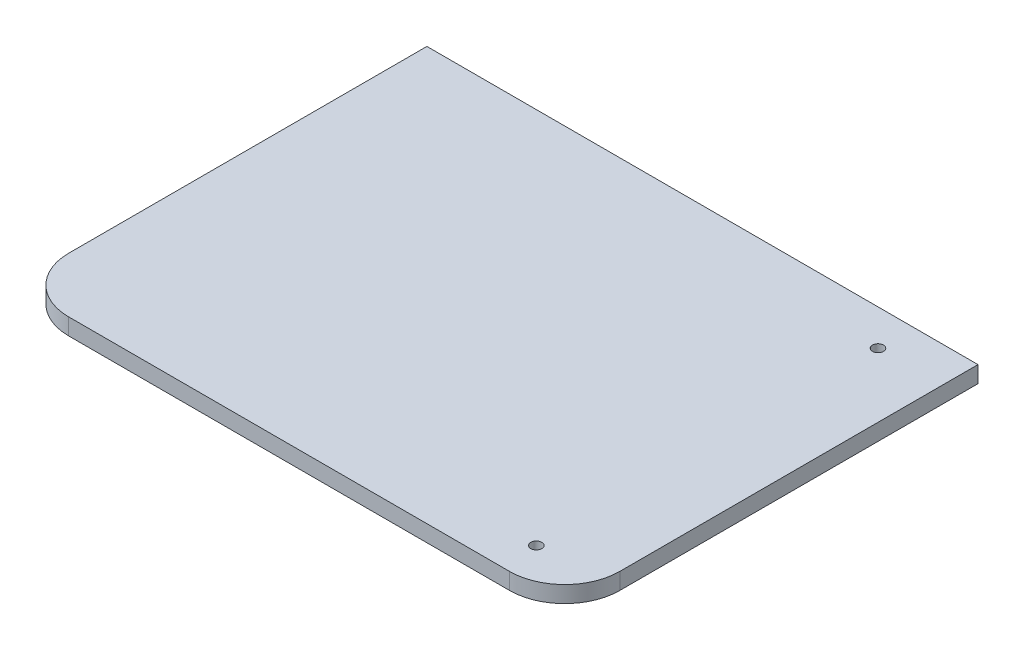
from build123d import *

# Parameters (mm, degrees)
SKETCH1_W           = 100
SKETCH1_H           = 75
BOSS_EXTRUDE1_DEPTH = 3
FILLET1_R           = 10
SKETCH2_R           = 1
CUT_EXTRUDE1_DEPTH  = 4


with BuildPart() as part:
    # Sketch1 → Boss-Extrude1 (new body)
    with BuildSketch(Plane(origin=(0, 0, 0), x_dir=(1, 0, 0), z_dir=(0, 1, 0))):
        Rectangle(SKETCH1_W, SKETCH1_H)
    extrude(amount=BOSS_EXTRUDE1_DEPTH)

    # Fillet1
    fillet1_edges = [part.edges().sort_by_distance(p)[0] for p in [
        (50, 1.5, 37.5),
        (-50, 1.5, 37.5),
    ]]
    fillet(fillet1_edges, radius=FILLET1_R)

    # Sketch2 → Cut-Extrude1 (cut, through all)
    with BuildSketch(Plane(origin=(0, 3, 0), x_dir=(1, 0, 0), z_dir=(0, 1, 0))):
        with Locations((38.351170888, -31)):
            Circle(SKETCH2_R)
    cut_extrude1 = extrude(amount=-CUT_EXTRUDE1_DEPTH, mode=Mode.SUBTRACT)

    # Mirror1: Cut-Extrude1 across plane
    add(cut_extrude1.mirror(Plane.XY), mode=Mode.SUBTRACT)


solid = part.part
